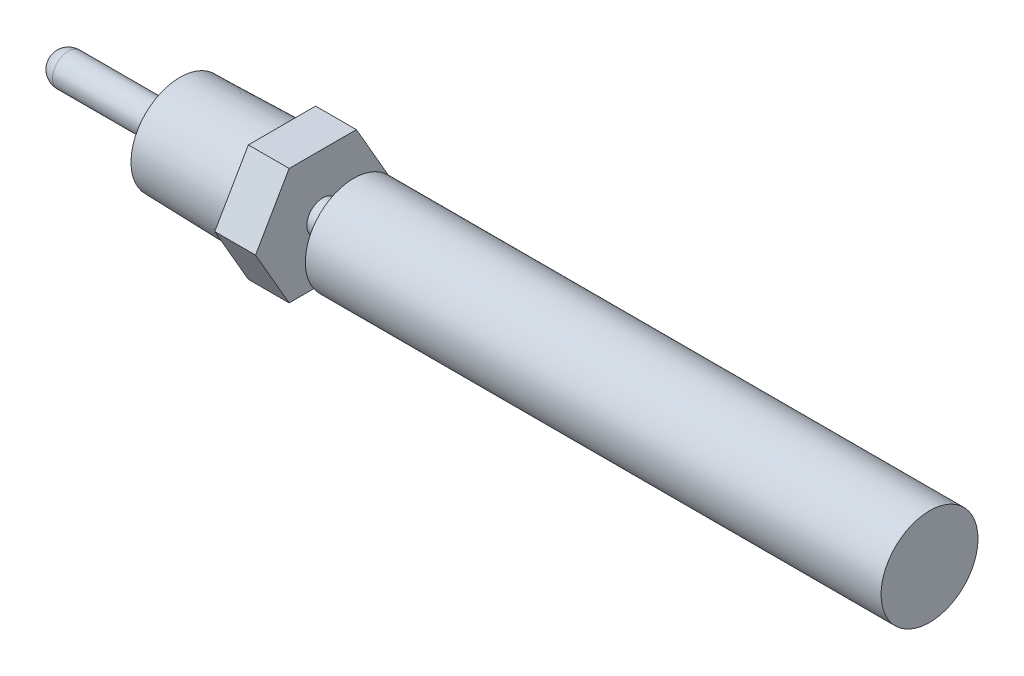
from build123d import *

# Parameters (mm, degrees)
CUT_EXTRUDE1_START = -4.064
SKETCH2_R          = 9.134112775
CUT_EXTRUDE1_DEPTH = 4.064


with BuildPart() as part:
    # Sketch1 → Revolve1 (revolve)
    with BuildSketch(Plane.XY):
        with BuildLine():
            Line((0, 1.5875), (11.1125, 1.5875))
            Line((11.1125, 1.5875), (11.1125, 4.882774376))
            Line((11.1125, 4.882774376), (21.2725, 5.1435))
            Line((21.2725, 5.1435), (21.2725, 6.699174823))
            Line((21.2725, 6.699174823), (25.3365, 6.699174823))
            Line((25.3365, 6.699174823), (25.3365, 1.5875))
            Line((25.3365, 1.5875), (28.426855679, 1.5875))
            Line((28.426855679, 1.5875), (28.426855679, 4.826))
            Line((28.426855679, 4.826), (85.7885, 4.826))
            Line((85.7885, 4.826), (85.7885, 0))
            Line((85.7885, 0), (0, 0))
            Line((0, 0), (-1.5875, 0))
            ThreePointArc((-1.5875, 0), (-1.122532015, 1.122532015), (0, 1.5875))
        make_face()
    revolve(axis=Axis((85.7885, 0, 0), (-1, 0, 0)))

    # Sketch2 → Cut-Extrude1 (cut)
    with BuildSketch(Plane(origin=(25.3365, 0, 0), x_dir=(0, 0, -1), z_dir=(1, 0, 0)).offset(CUT_EXTRUDE1_START)):
        Circle(SKETCH2_R)
        Polygon((6.699174823, 0), (3.349587412, 5.801655581), (-3.349587412, 5.801655581), (-6.699174823, 0), (-3.349587412, -5.801655581), (3.349587412, -5.801655581), align=None, mode=Mode.SUBTRACT)
    extrude(amount=CUT_EXTRUDE1_DEPTH, mode=Mode.SUBTRACT)


solid = part.part
